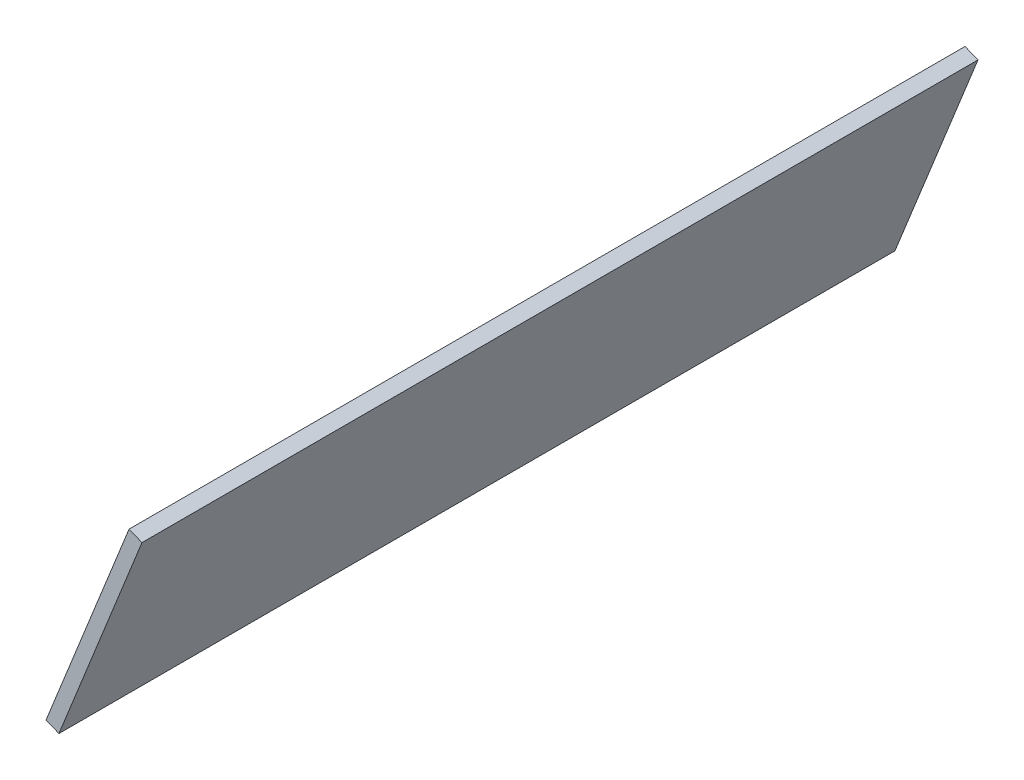
from build123d import *

# Parameters (mm, degrees)
BOSS_EXTRU_1_DEPTH = 600


with BuildPart() as part:
    # Esquisse1 → Boss.-Extru.1 (new body)
    with BuildSketch(Plane.XY):
        Polygon((-71.084194368, 377.679371173), (-130.685869423, 229.202761013), (-121.405657766, 225.477486312), (-61.803982711, 373.954096471), align=None)
    extrude(amount=BOSS_EXTRU_1_DEPTH)


solid = part.part
